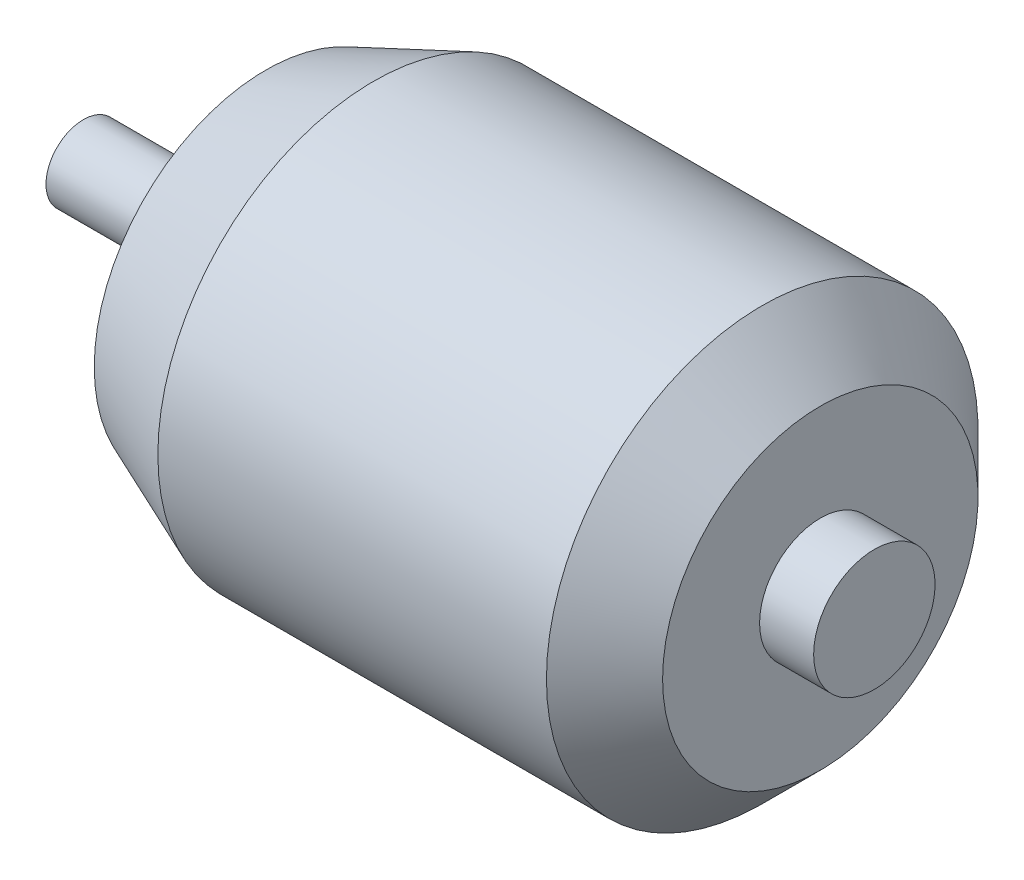
from build123d import *


with BuildPart() as part:
    # Sketch1 → Revolve1 (revolve)
    with BuildSketch(Plane.XY):
        Polygon((-48.594277419, 0), (-48.594277419, 4.290149626), (-27.675590362, 4.290149626), (-27.675590362, 19.674688279), (-15.304518043, 24.75), (29.263063004, 24.75), (35.924409638, 18.088653367), (35.924409638, 6.962328178), (42.124409638, 6.962328178), (42.124409638, 0), align=None)
    revolve(axis=Axis((-68.422942643, 0, 0), (1, 0, 0)))


solid = part.part
